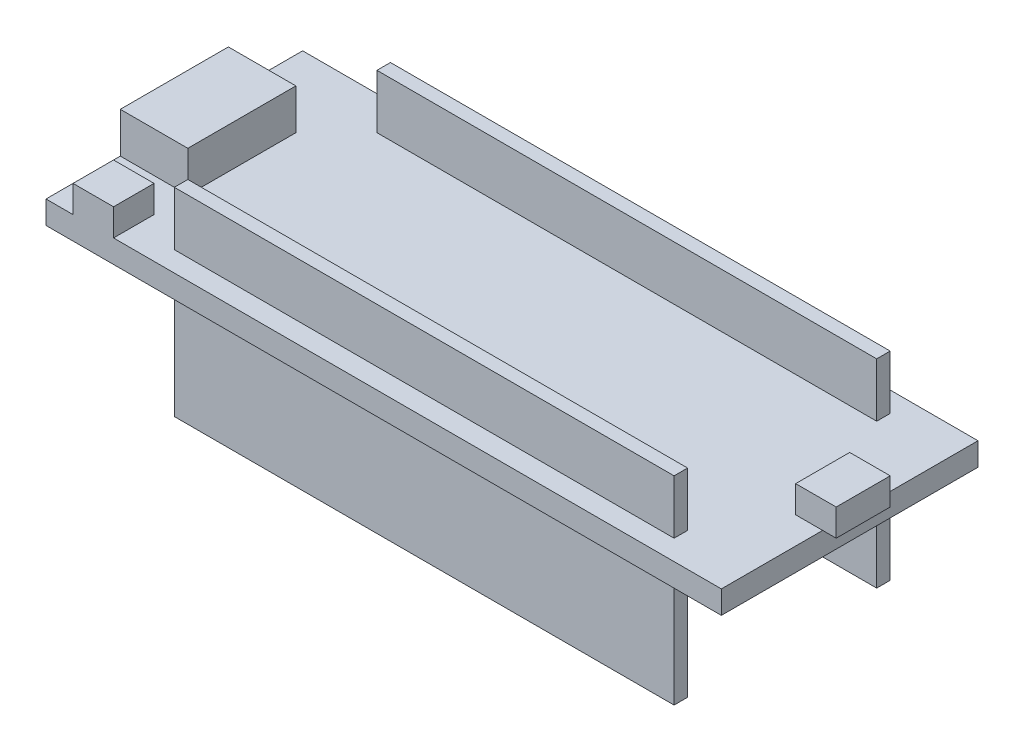
from build123d import *

# Parameters (mm, degrees)
SKETCH_1_W           = 50
SKETCH_1_H           = 19
EXTRUDE_1_DEPTH      = 1.7
SKETCH_2_W           = 5
SKETCH_2_H           = 8
EXTRUDE_2_DEPTH      = 3
SKETCH_3_W           = 3
SKETCH_3_H           = 3
EXTRUDE_3_DEPTH      = 2
SKETCH_4_W           = 37
SKETCH_4_H           = 1
EXTRUDE_4_DEPTH      = 4
EXTRUDE_4_DEPTH_BACK = 10.7
SKETCH_6_W           = 3
SKETCH_6_H           = 2
EXTRUDE_6_DEPTH      = 1
SKETCH_7_W           = 3
SKETCH_7_H           = 4
EXTRUDE_7_DEPTH      = 2


with BuildPart() as part:
    # Эскиз1 → Бобышка-Вытянуть1 (new body)
    with BuildSketch(Plane(origin=(0, 0, 0), x_dir=(1, 0, 0), z_dir=(0, 1, 0))):
        Rectangle(SKETCH_1_W, SKETCH_1_H)
    extrude(amount=EXTRUDE_1_DEPTH)

    # Эскиз2 → Бобышка-Вытянуть2 (add)
    with BuildSketch(Plane(origin=(0, 1.7, 0), x_dir=(1, 0, 0), z_dir=(0, 1, 0))):
        with Locations((-22.5, 0)):
            Rectangle(SKETCH_2_W, SKETCH_2_H)
    extrude(amount=EXTRUDE_2_DEPTH)

    # Эскиз3 → Бобышка-Вытянуть3 (add)
    with BuildSketch(Plane(origin=(0, 1.7, 0), x_dir=(1, 0, 0), z_dir=(0, 1, 0))):
        with Locations((-21.5, -8)):
            Rectangle(SKETCH_3_W, SKETCH_3_H)
    extrude(amount=EXTRUDE_3_DEPTH)

    # Эскиз4 → Бобышка-Вытянуть4 (add, two sides)
    with BuildSketch(Plane(origin=(0, 1.7, 0), x_dir=(1, 0, 0), z_dir=(0, 1, 0))) as extrude_4_sk:
        with Locations((1.5, 7.5)):
            Rectangle(SKETCH_4_W, SKETCH_4_H)
        with Locations((1.5, -7.5)):
            Rectangle(SKETCH_4_W, SKETCH_4_H)
    extrude(amount=EXTRUDE_4_DEPTH)
    extrude(extrude_4_sk.sketch, amount=-EXTRUDE_4_DEPTH_BACK)

    # Эскиз6 → Бобышка-Вытянуть6 (add)
    with BuildSketch(Plane.XZ):
        with Locations((-23.5, 0)):
            Rectangle(SKETCH_6_W, SKETCH_6_H)
    extrude(amount=EXTRUDE_6_DEPTH)

    # Эскиз7 → Бобышка-Вытянуть7 (add)
    with BuildSketch(Plane(origin=(0, 1.7, 0), x_dir=(1, 0, 0), z_dir=(0, 1, 0))):
        with Locations((24.5, 0)):
            Rectangle(SKETCH_7_W, SKETCH_7_H)
    extrude(amount=EXTRUDE_7_DEPTH)


solid = part.part
